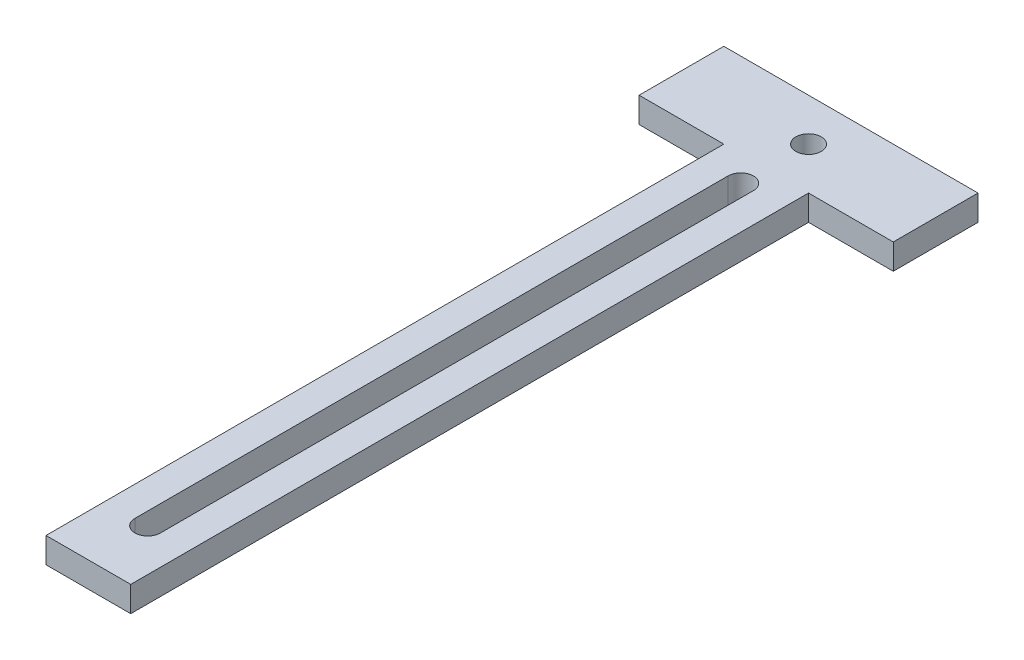
from build123d import *

# Parameters (mm, degrees)
SKETCH1_W           = 30
SKETCH1_H           = 10
SKETCH1_R           = 1.5
BOSS_EXTRUDE1_DEPTH = 3
SKETCH2_W           = 10
SKETCH2_H           = 80
BOSS_EXTRUDE2_DEPTH = 3


with BuildPart() as part:
    # Sketch1 → Boss-Extrude1 (new body)
    with BuildSketch(Plane(origin=(0, 0, 0), x_dir=(1, 0, 0), z_dir=(0, 1, 0))):
        Rectangle(SKETCH1_W, SKETCH1_H)
        Circle(SKETCH1_R, mode=Mode.SUBTRACT)
    extrude(amount=BOSS_EXTRUDE1_DEPTH)

    # Sketch2 → Boss-Extrude2 (add)
    with BuildSketch(Plane(origin=(0, 0, 0), x_dir=(1, 0, 0), z_dir=(0, 1, 0))):
        with Locations((0, -45)):
            Rectangle(SKETCH2_W, SKETCH2_H)
        with BuildLine():
            Line((-1.5, -8), (-1.5, -78))
            ThreePointArc((-1.5, -78), (0, -79.5), (1.5, -78))
            Line((1.5, -78), (1.5, -8))
            ThreePointArc((1.5, -8), (0, -6.5), (-1.5, -8))
        make_face(mode=Mode.SUBTRACT)
    extrude(amount=BOSS_EXTRUDE2_DEPTH)


solid = part.part
